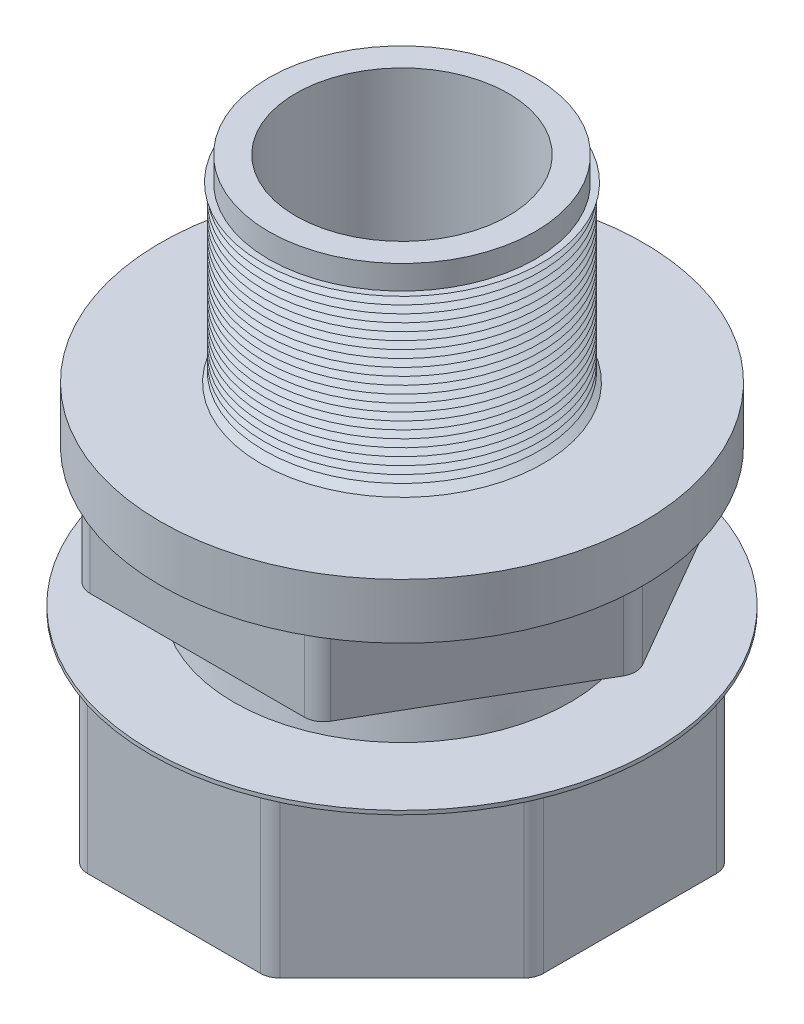
from build123d import *

# Parameters (mm, degrees)
SKETCH20_R         = 8.73125
CUT_EXTRUDE5_DEPTH = 13.0048
SKETCH2_OUTSIDE_W  = 44.726
SKETCH2_OUTSIDE_H  = 44.726
CUT_EXTRUDE1_DEPTH = 12.954
SKETCH4_OUTSIDE_W  = 47.17
SKETCH4_OUTSIDE_H  = 47.17
CUT_EXTRUDE3_DEPTH = 5.1816
FILLET5_R          = 1.27
FILLET6_R          = 1.27
LPATTERN1_COUNT    = 5
LPATTERN1_PITCH    = 0.508
LPATTERN2_COUNT    = 22
LPATTERN2_PITCH    = 0.508


with BuildPart() as part:
    # Sketch1 → Revolve1 (revolve)
    with BuildSketch(Plane.XY, mode=Mode.PRIVATE) as revolve1_sk:
        Polygon((-6.985, 0), (-10.6426, 0), (-11.938, 1.2954), (-11.938, 2.5908), (-16.51, 2.5908), (-16.51, 13.208), (-6.985, 13.208), align=None)
    revolve(revolve1_sk.sketch.rotate(Axis((0, 57.39150146, 0), (0, -1, 0)), 270), axis=Axis((0, 57.39150146, 0), (0, -1, 0)))  # turned: the seam where the file's is

    # Sketch20 → Cut-Extrude5 (cut)
    with BuildSketch(Plane.XZ):
        with Locations(Location((0, 0, 0), (0, 0, 270))):  # turned: the seam where the file's is
            Circle(SKETCH20_R)
    extrude(amount=-CUT_EXTRUDE5_DEPTH, mode=Mode.SUBTRACT)

    # Sketch2 outside → Cut-Extrude1 (cut)
    with BuildSketch(Plane.XZ):
        Rectangle(SKETCH2_OUTSIDE_W, SKETCH2_OUTSIDE_H)
        Polygon((6.207404446, 14.986), (-6.207404446, 14.986), (-14.986, 6.207404446), (-14.986, -6.207404446), (-6.207404446, -14.986), (6.207404446, -14.986), (14.986, -6.207404446), (14.986, 6.207404446), align=None, mode=Mode.SUBTRACT)
    extrude(amount=-CUT_EXTRUDE1_DEPTH, mode=Mode.SUBTRACT)

    # Fillet5
    fillet5_edges = [part.edges().sort_by_distance(p)[0] for p in [
        (14.986, 7.7724, 6.207404446),
        (14.986, 7.7724, -6.207404446),
        (6.207404446, 7.7724, -14.986),
        (-6.207404446, 7.7724, -14.986),
        (-14.986, 7.7724, -6.207404446),
        (-14.986, 7.7724, 6.207404446),
        (-6.207404446, 7.7724, 14.986),
        (6.207404446, 7.7724, 14.986),
    ]]
    fillet(fillet5_edges, radius=FILLET5_R)


with BuildPart() as body_2:
    # Sketch3 → Revolve2 (revolve)
    with BuildSketch(Plane.XY, mode=Mode.PRIVATE) as revolve2_sk:
        Polygon((-11.049, 17.0942), (-11.049, 13.208), (-6.985, 13.208), (-6.985, 38.862), (-8.759425119, 38.862), (-8.759425119, 37.2872), (-9.267425119, 37.2872), (-9.271, 25.908), (-15.875, 25.908), (-15.875, 17.0942), align=None)
    revolve(revolve2_sk.sketch.rotate(Axis((0, 46.826463668, 0), (0, -1, 0)), 270), axis=Axis((0, 46.826463668, 0), (0, -1, 0)))  # turned: the seam where the file's is

    # Sketch4 outside → Cut-Extrude3 (cut)
    with BuildSketch(Plane.XZ.offset(-17.0942)):
        Rectangle(SKETCH4_OUTSIDE_W, SKETCH4_OUTSIDE_H)
        Polygon((-15.544578648, 0), (-7.772289324, -13.462), (7.772289324, -13.462), (15.544578648, 0), (7.772289324, 13.462), (-7.772289324, 13.462), align=None, mode=Mode.SUBTRACT)
    extrude(amount=-CUT_EXTRUDE3_DEPTH, mode=Mode.SUBTRACT)

    # Fillet6
    fillet6_edges = [body_2.edges().sort_by_distance(p)[0] for p in [
        (-7.772289324, 19.685, 13.462),
        (7.772289324, 19.685, 13.462),
        (15.544578648, 19.685, 0),
        (7.772289324, 19.685, -13.462),
        (-7.772289324, 19.685, -13.462),
        (-15.544578648, 19.685, 0),
    ]]
    fillet(fillet6_edges, radius=FILLET6_R)

    # Sketch7 → Cut-Revolve2 (revolve, cut)
    with BuildSketch(Plane.XY, mode=Mode.PRIVATE) as cut_revolve2_sk:
        Polygon((-11.049, 13.208), (-11.049, 15.640429402), (-10.609102891, 15.803868387), align=None)
    cut_revolve2 = revolve(cut_revolve2_sk.sketch.rotate(Axis((0, 57.39150146, 0), (0, -1, 0)), 270), axis=Axis((0, 57.39150146, 0), (0, -1, 0)), mode=Mode.SUBTRACT)  # turned: the seam where the file's is

    # LPattern1: Cut-Revolve2 ×5
    with Locations(*[(0, i * LPATTERN1_PITCH, 0) for i in range(1, LPATTERN1_COUNT)]):
        add(cut_revolve2, mode=Mode.SUBTRACT)

    # Sketch8 → Cut-Revolve3 (revolve, cut)
    with BuildSketch(Plane.XY, mode=Mode.PRIVATE) as cut_revolve3_sk:
        Polygon((-9.271, 25.908), (-9.270760611, 26.669999962), (-8.61096898, 26.288792664), align=None)
    cut_revolve3 = revolve(cut_revolve3_sk.sketch.rotate(Axis((0, 57.39150146, 0), (0, -1, 0)), 270), axis=Axis((0, 57.39150146, 0), (0, -1, 0)), mode=Mode.SUBTRACT)  # turned: the seam where the file's is

    # LPattern2: Cut-Revolve3 ×22
    with Locations(*[(0, i * LPATTERN2_PITCH, 0) for i in range(1, LPATTERN2_COUNT)]):
        add(cut_revolve3, mode=Mode.SUBTRACT)


solid = Compound([part.part, body_2.part])
